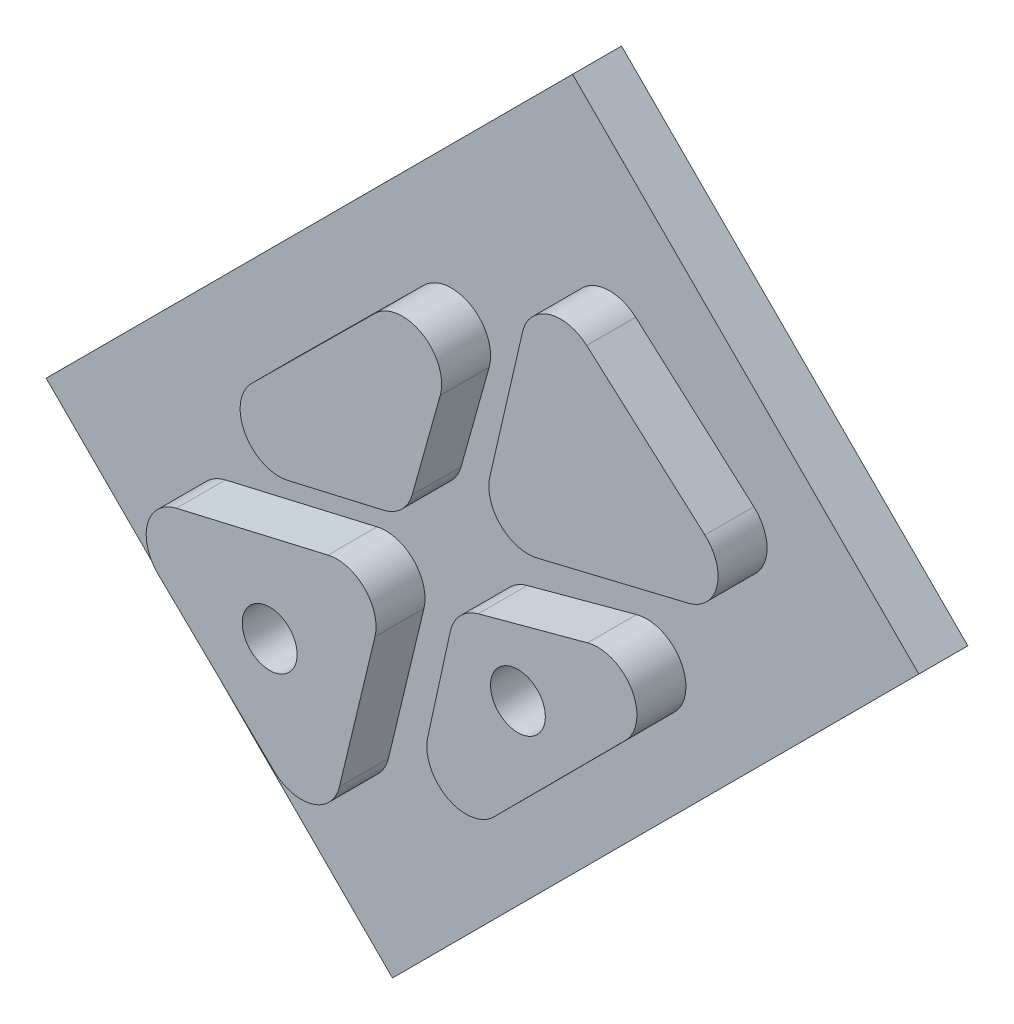
from build123d import *

# Parameters (mm, degrees)
BOSS_EXTRUDE1_DEPTH     = 6.35
BOSS_EXTRUDE2_DEPTH     = 6.35
FILLET1_R               = 5.08
SKETCH3_R               = 3.556
CUT_EXTRUDE1_DEPTH      = 1.0000001
CUT_EXTRUDE1_DEPTH_BACK = 13.7


with BuildPart() as part:
    # Sketch1 → Boss-Extrude1 (new body)
    with BuildSketch(Plane.XY):
        Polygon((187.286286244, -255.536232765), (255.536232765, -187.286286244), (300.43751337, -232.18756685), (232.18756685, -300.43751337), align=None)
    extrude(amount=BOSS_EXTRUDE1_DEPTH)

    # Sketch2 → Boss-Extrude2 (add)
    with BuildSketch(Plane(origin=(-122.999277868, -379.350906339, 6.35), x_dir=(1, 0, 0), z_dir=(0, 0, 1))):
        Polygon((358.652446232, 129.843073159), (361.187345435, 130.431571088), (353.631906688, 99.023102123), (352.465526746, 94.616733593), (347.736029271, 99.326506792), (324.454742757, 121.903791925), align=None)
        Polygon((369.84495619, 105.077454433), (362.389303407, 97.597844709), (364.454204898, 107.026485871), (369.687373927, 130.92189838), (389.915729798, 136.377665107), (404.528274707, 139.872219424), align=None)
        Polygon((380.244489791, 174.237534533), (380.323081857, 174.55732413), (406.948495143, 150.901624736), (409.197553318, 148.774137273), (405.612483177, 147.90877996), (372.317989901, 139.872219424), align=None)
        Polygon((371.079053541, 165.746977866), (363.278943376, 137.878777762), (341.260989988, 132.802884769), (330.489965122, 130.230836291), (365.380288676, 164.810357377), (373.055677454, 172.41737391), align=None)
    extrude(amount=BOSS_EXTRUDE2_DEPTH)

    # Fillet1
    fillet1_edges = [part.edges().sort_by_distance(p)[0] for p in [
        (250.056399586, -206.933532429, 9.525),
        (257.323803989, -204.79358221, 9.525),
        (286.19827545, -230.576769066, 9.525),
        (249.318712034, -239.478686915, 9.525),
        (239.390025539, -281.753061631, 9.525),
        (246.688096059, -248.429007959, 9.525),
        (281.528996839, -239.478686915, 9.525),
        (201.455464889, -257.447114414, 9.525),
        (238.188067567, -248.919335251, 9.525),
        (207.490687255, -249.120070049, 9.525),
        (240.279665508, -241.472128577, 9.525),
        (229.466248878, -284.734172747, 9.525),
    ]]
    fillet(fillet1_edges, radius=FILLET1_R)

    # Sketch3 → Cut-Extrude1 (cut, two sides)
    with BuildSketch(Plane.XY.offset(12.7)) as cut_extrude1_sk:
        with Locations((254.802658362, -254.853889617)):
            Circle(SKETCH3_R)
        with Locations((222.616120289, -263.9547)):
            Circle(SKETCH3_R)
    extrude(amount=CUT_EXTRUDE1_DEPTH, mode=Mode.SUBTRACT)
    extrude(cut_extrude1_sk.sketch, amount=-CUT_EXTRUDE1_DEPTH_BACK, mode=Mode.SUBTRACT)


solid = part.part
